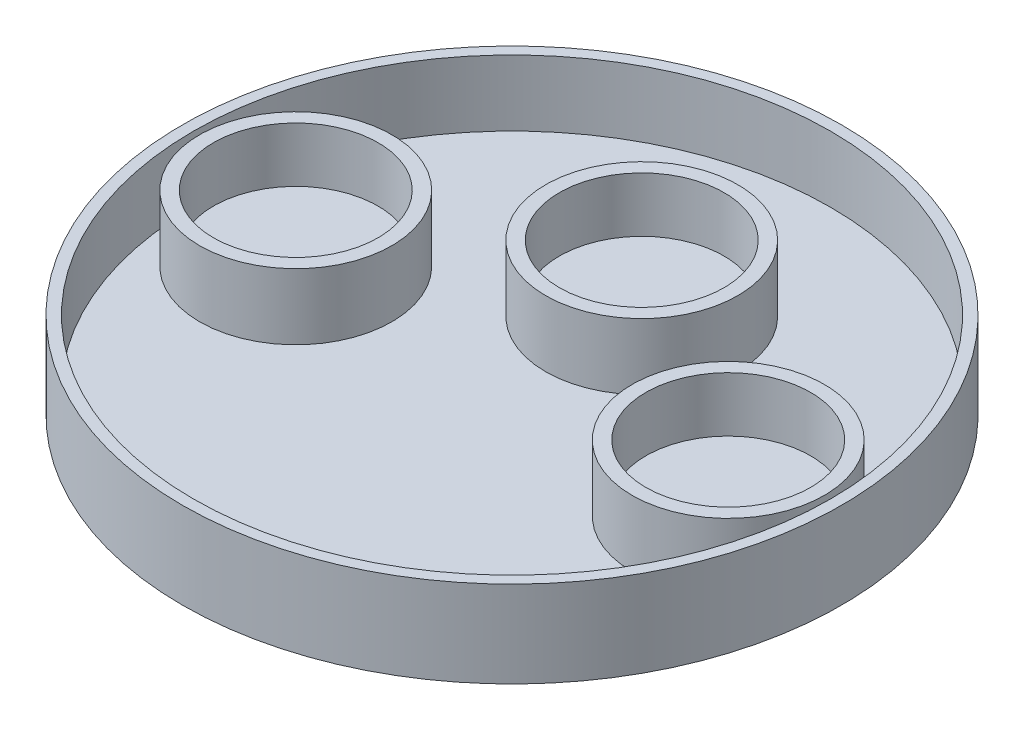
from build123d import *

# Parameters (mm, degrees)
SKETCH1_R           = 38.1
BOSS_EXTRUDE1_DEPTH = 10
SKETCH2_R           = 9.525
CUT_EXTRUDE1_DEPTH  = 6.35
SKETCH3_R           = 36.83
SKETCH3_R_2         = 11.1125
SKETCH3_R_3         = 11.115
CUT_EXTRUDE2_DEPTH  = 7.62


with BuildPart() as part:
    # Sketch1 → Boss-Extrude1 (new body)
    with BuildSketch(Plane(origin=(0, 0, 0), x_dir=(1, 0, 0), z_dir=(0, 1, 0))):
        Circle(SKETCH1_R)
    extrude(amount=BOSS_EXTRUDE1_DEPTH)

    # Sketch2 → Cut-Extrude1 (cut)
    with BuildSketch(Plane(origin=(0, 10, 0), x_dir=(1, 0, 0), z_dir=(0, 1, 0))):
        with Locations((25, 0)):
            Circle(SKETCH2_R)
        with Locations((-25, 0)):
            Circle(SKETCH2_R)
        with Locations((0, 15)):
            Circle(SKETCH2_R)
    extrude(amount=-CUT_EXTRUDE1_DEPTH, mode=Mode.SUBTRACT)

    # Sketch3 → Cut-Extrude2 (cut)
    with BuildSketch(Plane(origin=(0, 10, 0), x_dir=(1, 0, 0), z_dir=(0, 1, 0))):
        Circle(SKETCH3_R)
        with Locations((0, 15)):
            Circle(SKETCH3_R_2, mode=Mode.SUBTRACT)
        with Locations((25, 0)):
            Circle(SKETCH3_R_3, mode=Mode.SUBTRACT)
        with Locations((-25, 0)):
            Circle(SKETCH3_R_3, mode=Mode.SUBTRACT)
    extrude(amount=-CUT_EXTRUDE2_DEPTH, mode=Mode.SUBTRACT)


solid = part.part
